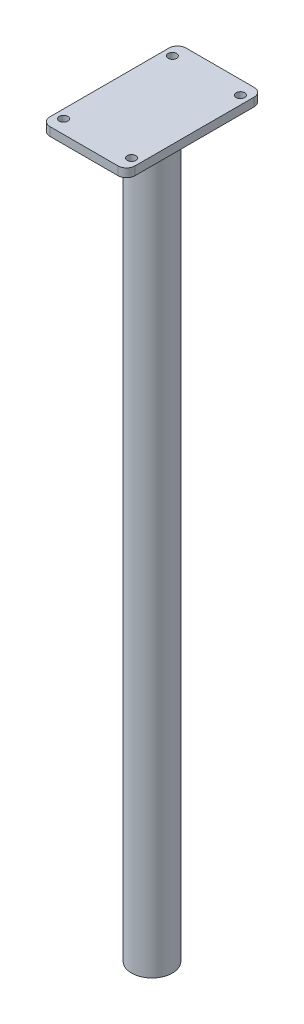
from build123d import *

# Parameters (mm, degrees)
SKETCH1_R           = 12
BOSS_EXTRUDE1_DEPTH = 430
SKETCH2_R           = 2.5
BOSS_EXTRUDE2_DEPTH = 5
SKETCH3_R           = 5
CUT_EXTRUDE1_DEPTH  = 50


with BuildPart() as part:
    # Sketch1 → Boss-Extrude1 (new body)
    with BuildSketch(Plane(origin=(0, 0, 0), x_dir=(1, 0, 0), z_dir=(0, 1, 0))):
        Circle(SKETCH1_R)
    extrude(amount=-BOSS_EXTRUDE1_DEPTH)

    # Sketch2 → Boss-Extrude2 (add)
    with BuildSketch(Plane(origin=(0, 0, 0), x_dir=(1, 0, 0), z_dir=(0, 1, 0))):
        with BuildLine():
            Line((-20, 40), (20, 40))
            ThreePointArc((20, 40), (23.535533906, 38.535533906), (25, 35))
            Line((25, 35), (25, -35))
            ThreePointArc((25, -35), (23.535533906, -38.535533906), (20, -40))
            Line((20, -40), (-20, -40))
            ThreePointArc((-20, -40), (-23.535533906, -38.535533906), (-25, -35))
            Line((-25, -35), (-25, 35))
            ThreePointArc((-25, 35), (-23.535533906, 38.535533906), (-20, 40))
        make_face()
        with Locations((-20, 32)):
            Circle(SKETCH2_R, mode=Mode.SUBTRACT)
        with Locations((-20, -32)):
            Circle(SKETCH2_R, mode=Mode.SUBTRACT)
        with Locations((20, -32)):
            Circle(SKETCH2_R, mode=Mode.SUBTRACT)
        with Locations((20, 32)):
            Circle(SKETCH2_R, mode=Mode.SUBTRACT)
    extrude(amount=BOSS_EXTRUDE2_DEPTH)

    # Sketch3 → Cut-Extrude1 (cut)
    with BuildSketch(Plane.XZ.offset(430)):
        Circle(SKETCH3_R)
    extrude(amount=-CUT_EXTRUDE1_DEPTH, mode=Mode.SUBTRACT)


solid = part.part
